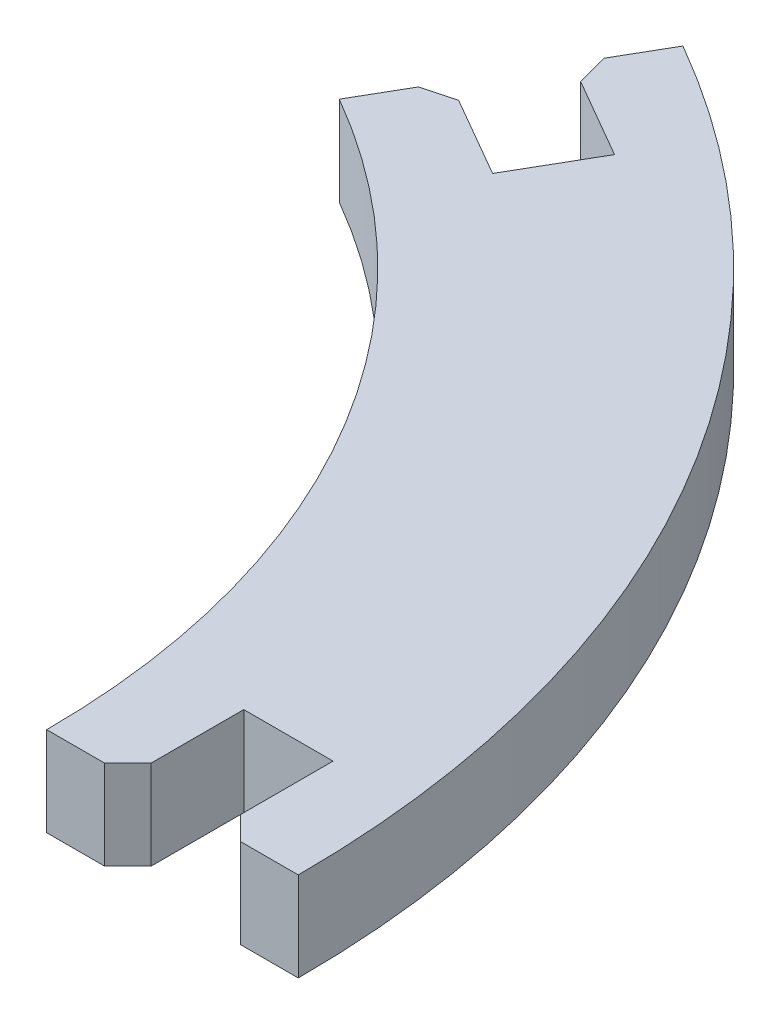
from build123d import *

# Parameters (mm, degrees)
BOSS_EXTRUDE1_DEPTH = 3.85
CHAMFER1_SIZE       = 1


with BuildPart() as part:
    # Sketch1 → Boss-Extrude1 (new body)
    with BuildSketch(Plane(origin=(0, 0, 0), x_dir=(1, 0, 0), z_dir=(0, 1, 0))):
        with BuildLine():
            Line((37.975, 0), (37.975, 5))
            Line((37.975, 5), (41.825, 5))
            Line((41.825, 5), (41.825, 0))
            Line((41.825, 0), (45.325, 0))
            ThreePointArc((45.325, 0), (39.252601427, 22.6625), (22.6625, 39.252601427))
            Line((22.6625, 39.252601427), (20.9125, 36.221512513))
            Line((20.9125, 36.221512513), (25.242627019, 33.721512513))
            Line((25.242627019, 33.721512513), (23.317627019, 30.387314709))
            Line((23.317627019, 30.387314709), (18.9875, 32.887314709))
            Line((18.9875, 32.887314709), (17.2375, 29.856225795))
            ThreePointArc((17.2375, 29.856225795), (29.856225795, 17.2375), (34.475, 0))
            Line((34.475, 0), (37.975, 0))
        make_face()
    extrude(amount=BOSS_EXTRUDE1_DEPTH)

    # Chamfer1
    chamfer1_edges = [part.edges().sort_by_distance(p)[0] for p in [
        (18.9875, 1.925, -32.887314709),
        (20.9125, 1.925, -36.221512513),
        (41.825, 1.925, 0),
        (37.975, 1.925, 0),
    ]]
    chamfer(chamfer1_edges, length=CHAMFER1_SIZE)


solid = part.part
